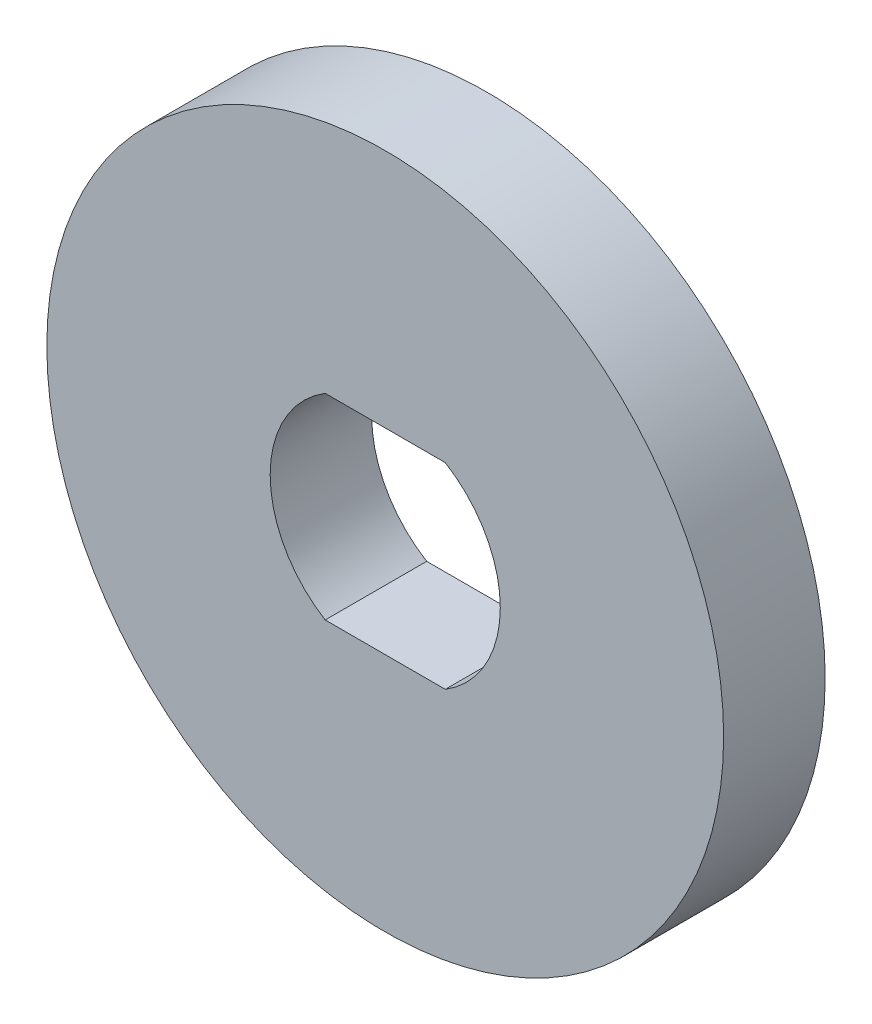
from build123d import *

# Parameters (mm, degrees)
SKETCH1_R           = 10
BOSS_EXTRUDE1_DEPTH = 3


with BuildPart() as part:
    # Sketch1 → Boss-Extrude1 (new body)
    with BuildSketch(Plane.XY):
        Circle(SKETCH1_R)
        with BuildLine():
            Line((-1.774823935, 2.9), (1.774823935, 2.9))
            ThreePointArc((1.774823935, 2.9), (3.4, 0), (1.774823935, -2.9))
            Line((1.774823935, -2.9), (-1.774823935, -2.9))
            ThreePointArc((-1.774823935, -2.9), (-3.4, 0), (-1.774823935, 2.9))
        make_face(mode=Mode.SUBTRACT)
    extrude(amount=BOSS_EXTRUDE1_DEPTH)


solid = part.part
